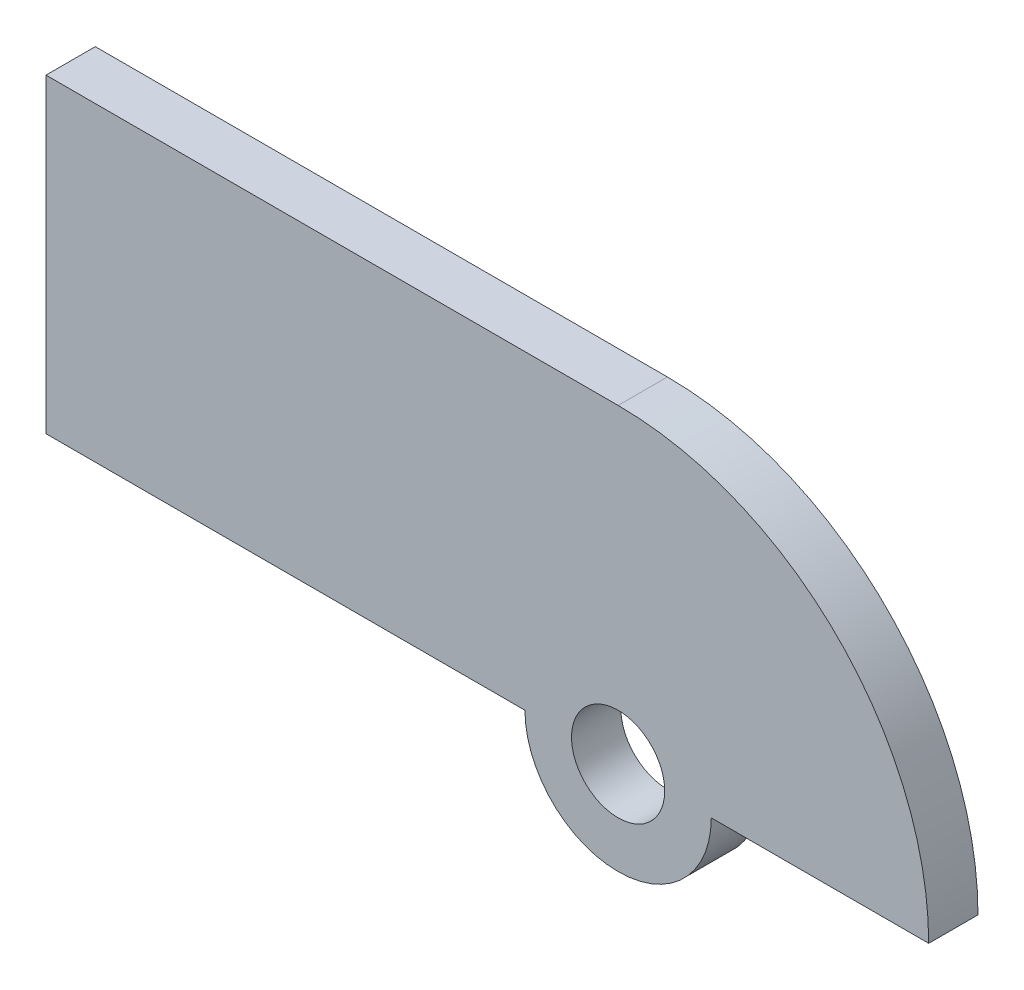
from build123d import *

# Parameters (mm, degrees)
SKETCH1_R           = 3
BOSS_EXTRUDE1_DEPTH = 3.175


with BuildPart() as part:
    # Sketch1 → Boss-Extrude1 (new body)
    with BuildSketch(Plane.XY):
        with BuildLine():
            ThreePointArc((-6, 0), (0, -6), (6, 0))
            Line((6, 0), (20, 0))
            ThreePointArc((20, 0), (14.142135624, 14.142135624), (0, 20))
            Line((0, 20), (-36.84213525, 20))
            Line((-36.84213525, 20), (-36.84213525, 0))
            Line((-36.84213525, 0), (-6, 0))
        make_face()
        Circle(SKETCH1_R, mode=Mode.SUBTRACT)
    extrude(amount=BOSS_EXTRUDE1_DEPTH)


solid = part.part
